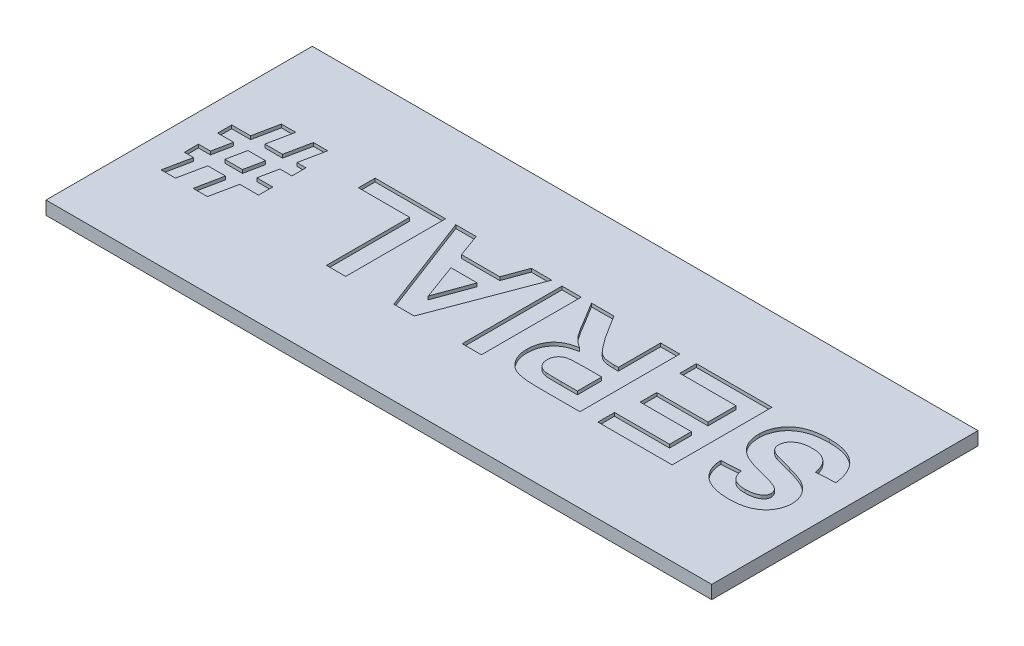
from build123d import *

# Parameters (mm, degrees)
SKETCH1_W           = 200
SKETCH1_H           = 80
BOSS_EXTRUDE1_DEPTH = 4
SKETCH2_W           = 5.769230769
SKETCH2_H           = 30
CUT_EXTRUDE1_DEPTH  = 1


with BuildPart() as part:
    # Sketch1 → Boss-Extrude1 (new body)
    with BuildSketch(Plane(origin=(0, 0, 0), x_dir=(1, 0, 0), z_dir=(0, 1, 0))):
        Rectangle(SKETCH1_W, SKETCH1_H)
    extrude(amount=BOSS_EXTRUDE1_DEPTH)

    # Sketch2 → Cut-Extrude1 (cut)
    with BuildSketch(Plane(origin=(0, 4, 0), x_dir=(-1, 0, 0), z_dir=(0, 1, 0))):
        with BuildLine():
            Line((-92.208944907, -5.128362554), (-86.439714137, -4.74374717))
            add(Edge.make_bspline(
                [(-86.439714137, -4.74374717), (-86.393752309, -4.985111469), (-86.304474381, -5.453946268), (-86.106115589, -6.122099863), (-85.887777456, -6.745008513), (-85.626851422, -7.315992563), (-85.341204064, -7.845606331), (-85.007369342, -8.318762402), (-84.648636412, -8.750567442), (-84.247247306, -9.125512858), (-83.809939084, -9.453895232), (-83.334529622, -9.733950661), (-82.826170389, -9.976343694), (-82.28361839, -10.175946672), (-81.701281795, -10.324951268), (-81.084233608, -10.430959205), (-80.431588869, -10.498843759), (-79.985558164, -10.508189425), (-79.75702183, -10.512977939)],
                knots=[0, 0, 0, 0, 0.000736638, 0.001430872, 0.002088588, 0.002715262, 0.003312395, 0.003890881, 0.004449517, 0.004993711, 0.005534576, 0.006087003, 0.006646124, 0.007222201, 0.007818366, 0.008446737, 0.009099133, 0.009784651, 0.009784651, 0.009784651, 0.009784651], degree=3))
            add(Edge.make_bspline(
                [(-79.75702183, -10.512977939), (-79.516472882, -10.510353565), (-79.048592788, -10.505249023), (-78.3705828, -10.441922689), (-77.736612665, -10.351200902), (-77.15228056, -10.207590441), (-76.606674643, -10.046984864), (-76.113345494, -9.827259325), (-75.664309875, -9.57383768), (-75.260724605, -9.286269773), (-74.90851536, -8.967336331), (-74.600385136, -8.634380166), (-74.332024066, -8.294594653), (-74.120804912, -7.932901599), (-73.949868083, -7.56392937), (-73.836890808, -7.176670886), (-73.760567971, -6.780018439), (-73.751815964, -6.508933527), (-73.747406445, -6.372352939)],
                knots=[0, 0, 0, 0, 0.000721379, 0.00140312, 0.002041413, 0.002640509, 0.003206945, 0.003745133, 0.00425648, 0.004751791, 0.00522841, 0.005679172, 0.006111906, 0.006524167, 0.006932997, 0.007328447, 0.007731584, 0.008140944, 0.008140944, 0.008140944, 0.008140944], degree=3))
            add(Edge.make_bspline(
                [(-73.747406445, -6.372352939), (-73.752814345, -6.201228541), (-73.763394111, -5.866448698), (-73.890763889, -5.387844242), (-74.081775379, -4.944431042), (-74.36937268, -4.542758314), (-74.755974239, -4.175687982), (-75.249123056, -3.83230267), (-75.862584608, -3.52339019), (-76.317693282, -3.351078232), (-76.559906445, -3.25937217)],
                knots=[0, 0, 0, 0, 0.000512088, 0.001001826, 0.001475329, 0.001953877, 0.002472378, 0.003067603, 0.003750296, 0.004527003, 0.004527003, 0.004527003, 0.004527003], degree=3))
            add(Edge.make_bspline(
                [(-76.559906445, -3.25937217), (-76.6638337, -3.224545667), (-76.896406018, -3.146609611), (-77.293149697, -3.035168399), (-77.771038003, -2.896007934), (-78.336976716, -2.737829851), (-78.990775544, -2.576055312), (-79.725132412, -2.376767434), (-80.548999942, -2.178459708), (-81.125378657, -2.032068989), (-81.427694907, -1.955285631)],
                knots=[0, 0, 0, 0, 0.000328776, 0.000735747, 0.001235991, 0.001822106, 0.002498421, 0.003256396, 0.004104689, 0.005040434, 0.005040434, 0.005040434, 0.005040434], degree=3))
            add(Edge.make_bspline(
                [(-81.427694907, -1.955285631), (-81.821400388, -1.856986561), (-82.580990733, -1.667334579), (-83.664340504, -1.32995714), (-84.662125457, -0.994753976), (-85.564738537, -0.631040557), (-86.382135942, -0.263466716), (-87.101096022, 0.133773662), (-87.736621898, 0.540050474), (-88.106957577, 0.843711689), (-88.28466606, 0.989425907)],
                knots=[0, 0, 0, 0, 0.001217107, 0.002348208, 0.003402977, 0.00437386, 0.005266627, 0.006089659, 0.006836401, 0.007525308, 0.007525308, 0.007525308, 0.007525308], degree=3))
            add(Edge.make_bspline(
                [(-88.28466606, 0.989425907), (-88.50504768, 1.19576827), (-88.937126224, 1.600321552), (-89.505890566, 2.265080238), (-89.983807486, 2.967291429), (-90.377185433, 3.701771872), (-90.680079012, 4.472749937), (-90.894766085, 5.275065019), (-91.03371936, 6.110811074), (-91.047898583, 6.679973937), (-91.055098753, 6.968993215)],
                knots=[0, 0, 0, 0, 0.00090522, 0.001774768, 0.002618194, 0.003448935, 0.004269176, 0.005097217, 0.005937017, 0.006803423, 0.006803423, 0.006803423, 0.006803423], degree=3))
            add(Edge.make_bspline(
                [(-91.055098753, 6.968993215), (-91.041076365, 7.342980714), (-91.013260133, 8.084860274), (-90.758167161, 9.175321958), (-90.360802012, 10.227533496), (-89.899952664, 11.063028422), (-89.457175871, 11.695083494), (-89.089481977, 12.148640428), (-88.685534711, 12.573126118), (-88.239800853, 12.958186011), (-87.768831605, 13.326375273), (-87.254379803, 13.653331746), (-86.711031717, 13.961306656), (-85.924745132, 14.326396584), (-84.857183705, 14.706856149), (-83.468228934, 15.027559417), (-81.955932227, 15.220343503), (-80.907452264, 15.243994035), (-80.363992984, 15.25625283)],
                knots=[0, 0, 0, 0, 0.001120515, 0.002222768, 0.003341138, 0.004486959, 0.005073812, 0.00565479, 0.006237103, 0.006829012, 0.007420402, 0.008028829, 0.008655733, 0.009292894, 0.010627327, 0.012047123, 0.013561785, 0.015191731, 0.015191731, 0.015191731, 0.015191731], degree=3))
            add(Edge.make_bspline(
                [(-80.363992984, 15.25625283), (-79.919008064, 15.250302266), (-79.05352191, 15.238728544), (-77.798899195, 15.121693248), (-76.627013508, 14.939541645), (-75.541977132, 14.678063871), (-74.543284516, 14.332583099), (-73.627064438, 13.92105018), (-72.79409546, 13.432457336), (-72.054518158, 12.864000712), (-71.395625669, 12.237313742), (-70.82084735, 11.552789688), (-70.327985703, 10.819073667), (-69.913859865, 10.036701876), (-69.588647936, 9.201651781), (-69.349792612, 8.314965357), (-69.19181163, 7.378729646), (-69.152213217, 6.737211584), (-69.13202183, 6.410098984)],
                knots=[0, 0, 0, 0, 0.001334622, 0.002595811, 0.003776467, 0.004890047, 0.005939134, 0.006942308, 0.007898762, 0.008829089, 0.009734469, 0.010621656, 0.011505049, 0.012381402, 0.013271962, 0.014187497, 0.015132001, 0.016114679, 0.016114679, 0.016114679, 0.016114679], degree=3))
            Line((-69.13202183, 6.410098984), (-74.901252599, 6.025483599))
            add(Edge.make_bspline(
                [(-74.901252599, 6.025483599), (-74.934533834, 6.206391204), (-74.9993955, 6.558961309), (-75.140422526, 7.063913332), (-75.299494168, 7.530936358), (-75.485679283, 7.960027391), (-75.710568404, 8.343501006), (-75.9553124, 8.693421482), (-76.226662634, 9.005126326), (-76.533603624, 9.270080057), (-76.86558756, 9.511177095), (-77.243932244, 9.70442195), (-77.652784622, 9.88371064), (-78.107699043, 10.018491769), (-78.5999395, 10.125405003), (-79.129792717, 10.204663527), (-79.698357008, 10.243361998), (-80.089508286, 10.251857517), (-80.291877599, 10.25625283)],
                knots=[0, 0, 0, 0, 0.000551577, 0.001074965, 0.001571005, 0.002031084, 0.002475348, 0.0029022, 0.003310942, 0.003711203, 0.004116395, 0.004538482, 0.004982747, 0.005454186, 0.005958707, 0.006493293, 0.007059761, 0.007667, 0.007667, 0.007667, 0.007667], degree=3))
            add(Edge.make_bspline(
                [(-80.291877599, 10.25625283), (-80.502286419, 10.252372492), (-80.911646178, 10.24482312), (-81.508192455, 10.198493736), (-82.067797621, 10.112974153), (-82.593210054, 10.001648871), (-83.083727929, 9.850198524), (-83.5383161, 9.665529634), (-83.959054347, 9.448117502), (-84.215602184, 9.277065143), (-84.342358368, 9.192550907)],
                knots=[0, 0, 0, 0, 0.000631267, 0.001228158, 0.00179335, 0.002328509, 0.002837946, 0.003331211, 0.003798919, 0.00425569, 0.00425569, 0.00425569, 0.00425569], degree=3))
            add(Edge.make_bspline(
                [(-84.342358368, 9.192550907), (-84.487420178, 9.077102059), (-84.768359878, 8.853513476), (-85.070710444, 8.409542571), (-85.252726183, 7.908090746), (-85.274633842, 7.553480088), (-85.285867984, 7.371637446)],
                knots=[0, 0, 0, 0, 0.000553472, 0.001071904, 0.00158894, 0.002133134, 0.002133134, 0.002133134, 0.002133134], degree=3))
            add(Edge.make_bspline(
                [(-85.285867984, 7.371637446), (-85.276680503, 7.201693423), (-85.258582629, 6.866930745), (-85.076042263, 6.391393115), (-84.795320048, 5.950773296), (-84.533031183, 5.711422835), (-84.396444907, 5.586781676)],
                knots=[0, 0, 0, 0, 0.000507697, 0.001000082, 0.00150849, 0.002060917, 0.002060917, 0.002060917, 0.002060917], degree=3))
            add(Edge.make_bspline(
                [(-84.396444907, 5.586781676), (-84.288046097, 5.505883311), (-84.045819876, 5.325109136), (-83.602109453, 5.095328059), (-83.066539328, 4.846461271), (-82.426899796, 4.603166508), (-81.687441889, 4.360323364), (-80.848120634, 4.106767049), (-79.908419816, 3.849806502), (-78.892291945, 3.600952799), (-77.860635967, 3.356343903), (-76.876155093, 3.088917341), (-75.960729455, 2.828197125), (-75.118603619, 2.554920031), (-74.345436581, 2.288885626), (-73.644984116, 2.015649133), (-73.012436643, 1.749547363), (-72.274816166, 1.383638578), (-71.438797542, 0.888000343), (-70.562555714, 0.167507507), (-69.787631631, -0.642373496), (-69.247685126, -1.406035417), (-68.87677013, -2.06280499), (-68.637940009, -2.586326814), (-68.431333219, -3.13798681), (-68.263155856, -3.718394603), (-68.141267734, -4.328366897), (-68.04039822, -4.963243498), (-67.988862115, -5.628297197), (-67.981776161, -6.081816496), (-67.978175676, -6.312256785)],
                knots=[0, 0, 0, 0, 0.000405192, 0.000905437, 0.001494318, 0.002177328, 0.002956495, 0.003829132, 0.00480739, 0.005878687, 0.006967489, 0.007987921, 0.008938885, 0.009822625, 0.01064368, 0.011391412, 0.01207793, 0.012701455, 0.013860937, 0.014984414, 0.016093917, 0.01721448, 0.017779512, 0.018354962, 0.018938761, 0.019545494, 0.020165447, 0.02080374, 0.021472997, 0.022164338, 0.022164338, 0.022164338, 0.022164338], degree=3))
            add(Edge.make_bspline(
                [(-67.978175676, -6.312256785), (-67.983126458, -6.524774252), (-67.992958232, -6.946813353), (-68.061665332, -7.573225923), (-68.167919141, -8.188514563), (-68.325211283, -8.793450615), (-68.533875359, -9.38684404), (-68.76881453, -9.977259145), (-69.062592733, -10.55182022), (-69.396952397, -11.11100314), (-69.765766298, -11.654388278), (-70.183700952, -12.155648691), (-70.626208512, -12.631507633), (-71.121564028, -13.055319661), (-71.639178191, -13.461401068), (-72.202726135, -13.821033585), (-72.799004753, -14.146469177), (-73.431784211, -14.435278129), (-74.103308065, -14.686949027), (-74.812704138, -14.910953624), (-75.566363668, -15.094284181), (-76.358002207, -15.251421563), (-77.190516798, -15.370920482), (-78.062866617, -15.454358514), (-78.975249977, -15.501412534), (-79.596712988, -15.509074905), (-79.91327183, -15.512977939)],
                knots=[0, 0, 0, 0, 0.000637473, 0.001265959, 0.001888411, 0.002509353, 0.003138414, 0.003774525, 0.004414175, 0.005071727, 0.00572851, 0.006381791, 0.00702793, 0.007675241, 0.00833515, 0.009000265, 0.009677968, 0.010371786, 0.011085008, 0.011828187, 0.012602145, 0.013410656, 0.014248647, 0.015124094, 0.016038819, 0.01698851, 0.01698851, 0.01698851, 0.01698851], degree=3))
            add(Edge.make_bspline(
                [(-79.91327183, -15.512977939), (-80.370333954, -15.505515623), (-81.260244751, -15.490986316), (-82.553125311, -15.360937587), (-83.765761687, -15.161888627), (-84.896179798, -14.873001441), (-85.945761293, -14.502135502), (-86.914027464, -14.045310557), (-87.796294924, -13.499797317), (-88.603491023, -12.878825397), (-89.324861142, -12.171079121), (-89.973518608, -11.391222727), (-90.540712845, -10.532233744), (-91.026071043, -9.595455736), (-91.441863894, -8.585952919), (-91.784772261, -7.503261741), (-92.042964239, -6.34221835), (-92.152661139, -5.539979028), (-92.208944907, -5.128362554)],
                knots=[0, 0, 0, 0, 0.001370838, 0.002669054, 0.003894146, 0.005054376, 0.006164448, 0.007228947, 0.008259662, 0.0092706, 0.010277798, 0.011285014, 0.012308414, 0.013359427, 0.014445323, 0.015579995, 0.016762424, 0.018008402, 0.018008402, 0.018008402, 0.018008402], degree=3))
        make_face()
        Polygon((-62.978175676, -15.128362554), (-62.978175676, 14.871637446), (-40.670483368, 14.871637446), (-40.670483368, 9.871637446), (-57.208944907, 9.871637446), (-57.208944907, 3.333175907), (-41.824329522, 3.333175907), (-41.824329522, -1.666824093), (-57.208944907, -1.666824093), (-57.208944907, -10.128362554), (-40.285867984, -10.128362554), (-40.285867984, -15.128362554), align=None)
        with BuildLine():
            Line((-35.285867984, -15.128362554), (-35.285867984, 14.871637446))
            Line((-35.285867984, 14.871637446), (-22.695723753, 14.871637446))
            add(Edge.make_bspline(
                [(-22.695723753, 14.871637446), (-22.313096825, 14.869279325), (-21.575704707, 14.864734794), (-20.509291844, 14.831595166), (-19.525819809, 14.762165719), (-18.620925901, 14.683536298), (-17.798956401, 14.569135558), (-17.056661388, 14.432084599), (-16.395290567, 14.273261431), (-15.805194145, 14.083044934), (-15.267146084, 13.865335544), (-14.765927914, 13.606200115), (-14.296028601, 13.302591115), (-13.850230944, 12.964973106), (-13.426647174, 12.592827327), (-13.036889709, 12.176304963), (-12.67416794, 11.721608162), (-12.338774533, 11.232520033), (-12.043313937, 10.711200193), (-11.773340524, 10.174390946), (-11.553571982, 9.616379836), (-11.372045165, 9.039795508), (-11.227038742, 8.445889807), (-11.126392033, 7.833152807), (-11.063559378, 7.202693581), (-11.057950298, 6.776836652), (-11.055098753, 6.560339369)],
                knots=[0, 0, 0, 0, 0.001147899, 0.002212212, 0.003200004, 0.004105364, 0.004936561, 0.005688556, 0.006369236, 0.006975493, 0.007546881, 0.008108643, 0.008665433, 0.009223131, 0.009785086, 0.010354764, 0.010931969, 0.011528709, 0.01213174, 0.01272839, 0.013329892, 0.013928595, 0.01454078, 0.015162216, 0.015790099, 0.016439388, 0.016439388, 0.016439388, 0.016439388], degree=3))
            add(Edge.make_bspline(
                [(-11.055098753, 6.560339369), (-11.060387942, 6.287613386), (-11.070724476, 5.754631644), (-11.165846726, 4.973446281), (-11.307127562, 4.22707943), (-11.508522302, 3.514497067), (-11.785435973, 2.844080172), (-12.106898896, 2.206437165), (-12.490297435, 1.603730946), (-12.933026814, 1.041936416), (-13.434690676, 0.520556279), (-13.997487507, 0.050320138), (-14.617399114, -0.370609803), (-15.298175586, -0.739806204), (-16.035076635, -1.055429123), (-16.83129771, -1.320984629), (-17.683234314, -1.537117225), (-18.275840945, -1.638814074), (-18.579137214, -1.690862554)],
                knots=[0, 0, 0, 0, 0.00081786, 0.001598324, 0.002357345, 0.00309533, 0.00381513, 0.004530047, 0.00523525, 0.005954197, 0.006672465, 0.00740191, 0.008150318, 0.00891675, 0.009721635, 0.010552115, 0.011432477, 0.012355399, 0.012355399, 0.012355399, 0.012355399], degree=3))
            add(Edge.make_bspline(
                [(-18.579137214, -1.690862554), (-18.28581566, -1.885132179), (-17.711745416, -2.265344301), (-16.917477908, -2.89155843), (-16.204414143, -3.548818593), (-15.66451823, -4.133295216), (-15.249663861, -4.647279621), (-14.915635212, -5.096815334), (-14.555331769, -5.614165735), (-14.172287318, -6.199611133), (-13.755178096, -6.847971728), (-13.319517145, -7.569171674), (-12.856187638, -8.356176281), (-12.544671987, -8.905938845), (-12.383223753, -9.190862554)],
                knots=[0, 0, 0, 0, 0.001055128, 0.00206503, 0.00303041, 0.003961823, 0.004448936, 0.005011437, 0.005641616, 0.00634, 0.007110193, 0.007954303, 0.008867488, 0.009849926, 0.009849926, 0.009849926, 0.009849926], degree=3))
            Line((-12.383223753, -9.190862554), (-8.747406445, -15.128362554))
            Line((-8.747406445, -15.128362554), (-15.490194907, -15.128362554))
            Line((-15.490194907, -15.128362554), (-19.75702183, -8.319468324))
            add(Edge.make_bspline(
                [(-19.75702183, -8.319468324), (-19.952979959, -8.046777024), (-20.327104314, -7.526153271), (-20.867175934, -6.786330021), (-21.361293537, -6.12775445), (-21.796307001, -5.540887472), (-22.194227824, -5.042368146), (-22.542973547, -4.623509009), (-22.83544067, -4.27532195), (-23.166367947, -3.930079454), (-23.5513667, -3.575266331), (-24.027964404, -3.231254815), (-24.517386028, -2.957012465), (-25.041762204, -2.747759101), (-25.64818741, -2.601853757), (-26.377206543, -2.508893505), (-27.251741667, -2.440308476), (-27.883855355, -2.437544609), (-28.224569907, -2.436054862)],
                knots=[0, 0, 0, 0, 0.001007395, 0.001923324, 0.002747847, 0.003477415, 0.00411469, 0.004661003, 0.005112725, 0.005478275, 0.006095162, 0.006680598, 0.007237453, 0.00777423, 0.008368909, 0.009103214, 0.009977112, 0.010998906, 0.010998906, 0.010998906, 0.010998906], degree=3))
            Line((-28.224569907, -2.436054862), (-29.516637214, -2.436054862))
            Line((-29.516637214, -2.436054862), (-29.516637214, -15.128362554))
            Line((-29.516637214, -15.128362554), (-35.285867984, -15.128362554))
        make_face()
        with BuildLine():
            Line((-29.516637214, 2.563945138), (-24.871204522, 2.563945138))
            add(Edge.make_bspline(
                [(-24.871204522, 2.563945138), (-24.512613491, 2.56471362), (-23.829436982, 2.566177709), (-22.857946398, 2.587384445), (-21.990078179, 2.605383829), (-21.23102587, 2.650608047), (-20.577393405, 2.69542951), (-20.031802838, 2.753681147), (-19.589657413, 2.822532706), (-19.14802845, 2.929578801), (-18.695650336, 3.116085485), (-18.213500859, 3.381725908), (-17.801419634, 3.726333573), (-17.444462114, 4.124734882), (-17.172153534, 4.593091857), (-16.958871508, 5.110538661), (-16.850733005, 5.688573424), (-16.833315093, 6.089226791), (-16.824329522, 6.295916292)],
                knots=[0, 0, 0, 0, 0.001075738, 0.002049463, 0.002915181, 0.003679561, 0.004330377, 0.004880544, 0.005325134, 0.00567203, 0.006241169, 0.006787549, 0.007316941, 0.007844967, 0.008383993, 0.00893416, 0.00951638, 0.010136798, 0.010136798, 0.010136798, 0.010136798], degree=3))
            add(Edge.make_bspline(
                [(-16.824329522, 6.295916292), (-16.83454892, 6.52714123), (-16.854265601, 6.973252466), (-17.009754151, 7.608073005), (-17.281153082, 8.168849548), (-17.653886823, 8.656507955), (-18.121795318, 9.068293745), (-18.679126075, 9.395162033), (-19.321738525, 9.63859997), (-19.785232122, 9.728501129), (-20.027454522, 9.775483599)],
                knots=[0, 0, 0, 0, 0.000693219, 0.001337454, 0.001944901, 0.002549488, 0.003166842, 0.003802755, 0.004478001, 0.005217184, 0.005217184, 0.005217184, 0.005217184], degree=3))
            add(Edge.make_bspline(
                [(-20.027454522, 9.775483599), (-20.107521382, 9.784281227), (-20.29729665, 9.805133452), (-20.632417277, 9.818525919), (-21.06091199, 9.839111599), (-21.587967293, 9.847524508), (-22.208874501, 9.862271596), (-22.92610262, 9.864979533), (-23.737372959, 9.873631203), (-24.310303616, 9.872326358), (-24.61279106, 9.871637446)],
                knots=[0, 0, 0, 0, 0.000241584, 0.000572604, 0.001005671, 0.001528646, 0.002153762, 0.002868931, 0.003680252, 0.004587703, 0.004587703, 0.004587703, 0.004587703], degree=3))
            Line((-24.61279106, 9.871637446), (-29.516637214, 9.871637446))
            Line((-29.516637214, 9.871637446), (-29.516637214, 2.563945138))
        make_face(mode=Mode.SUBTRACT)
        with Locations((-2.785867984, -0.128362554)):
            Rectangle(SKETCH2_W, SKETCH2_H)
        Polygon((32.021824324, -15.128362554), (25.904035863, -15.128362554), (23.373987786, -8.205285631), (11.859564709, -8.205285631), (9.329516632, -15.128362554), (3.175670478, -15.128362554), (14.515814709, 14.871637446), (20.627593555, 14.871637446), align=None)
        Polygon((21.541055093, -3.205285631), (17.598747401, 7.563945138), (13.66845894, -3.205285631), align=None, mode=Mode.SUBTRACT)
        Polygon((35.098747401, -15.128362554), (35.098747401, 14.871637446), (40.86797817, 14.871637446), (40.86797817, -10.128362554), (56.252593555, -10.128362554), (56.252593555, -15.128362554), align=None)
        Polygon((72.063891632, -7.436054862), (69.329516632, -7.436054862), (69.329516632, -3.205285631), (72.929276247, -3.205285631), (74.113170478, 2.563945138), (69.329516632, 2.563945138), (69.329516632, 6.794714369), (74.978555093, 6.794714369), (76.63720894, 14.871637446), (80.940093555, 14.871637446), (79.281439709, 6.794714369), (84.593939709, 6.794714369), (86.252593555, 14.871637446), (90.55547817, 14.871637446), (88.896824324, 6.794714369), (91.63720894, 6.794714369), (91.63720894, 2.563945138), (88.031439709, 2.563945138), (86.847545478, -3.205285631), (91.63720894, -3.205285631), (91.63720894, -7.436054862), (85.982160863, -7.436054862), (84.401632016, -15.128362554), (80.098747401, -15.128362554), (81.679276247, -7.436054862), (76.366776247, -7.436054862), (74.786247401, -15.128362554), (70.483362786, -15.128362554), align=None)
        Polygon((78.416055093, 2.563945138), (77.232160863, -3.205285631), (82.544660863, -3.205285631), (83.728555093, 2.563945138), align=None, mode=Mode.SUBTRACT)
    extrude(amount=-CUT_EXTRUDE1_DEPTH, mode=Mode.SUBTRACT)


solid = part.part
